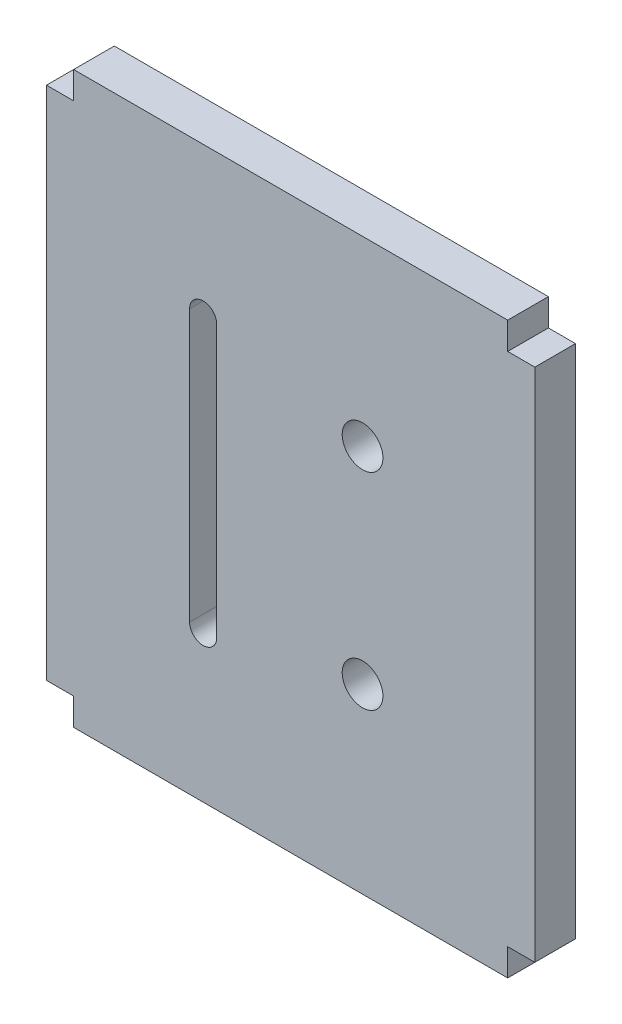
from build123d import *

# Parameters (mm, degrees)
SKETCH_1_W          = 32
SKETCH_1_H          = 42
SKETCH_1_W_2        = 2
SKETCH_1_H_2        = 38
EXTRUDE_1_DEPTH     = 3
SKETCH_2_R          = 1.5
CUT_EXTRUDE_1_DEPTH = 10


with BuildPart() as part:
    # 草图1 → 凸台-拉伸1 (new body)
    with BuildSketch(Plane.XY):
        Rectangle(SKETCH_1_W, SKETCH_1_H)
        with Locations((-17, 0)):
            Rectangle(SKETCH_1_W_2, SKETCH_1_H_2)
        with Locations((17, 0)):
            Rectangle(SKETCH_1_W_2, SKETCH_1_H_2)
    extrude(amount=EXTRUDE_1_DEPTH)

    # 草图2 → 切除-拉伸1 (cut)
    with BuildSketch(Plane.XY.offset(3)):
        with Locations((5.3, -7.6)):
            Circle(SKETCH_2_R)
        with Locations((5.3, 7.6)):
            Circle(SKETCH_2_R)
        with BuildLine():
            Line((-7.45, -10), (-7.45, 10))
            ThreePointArc((-7.45, 10), (-6.45, 11), (-5.45, 10))
            Line((-5.45, 10), (-5.45, -10))
            ThreePointArc((-5.45, -10), (-6.45, -11), (-7.45, -10))
        make_face()
    extrude(amount=-CUT_EXTRUDE_1_DEPTH, mode=Mode.SUBTRACT)


solid = part.part
